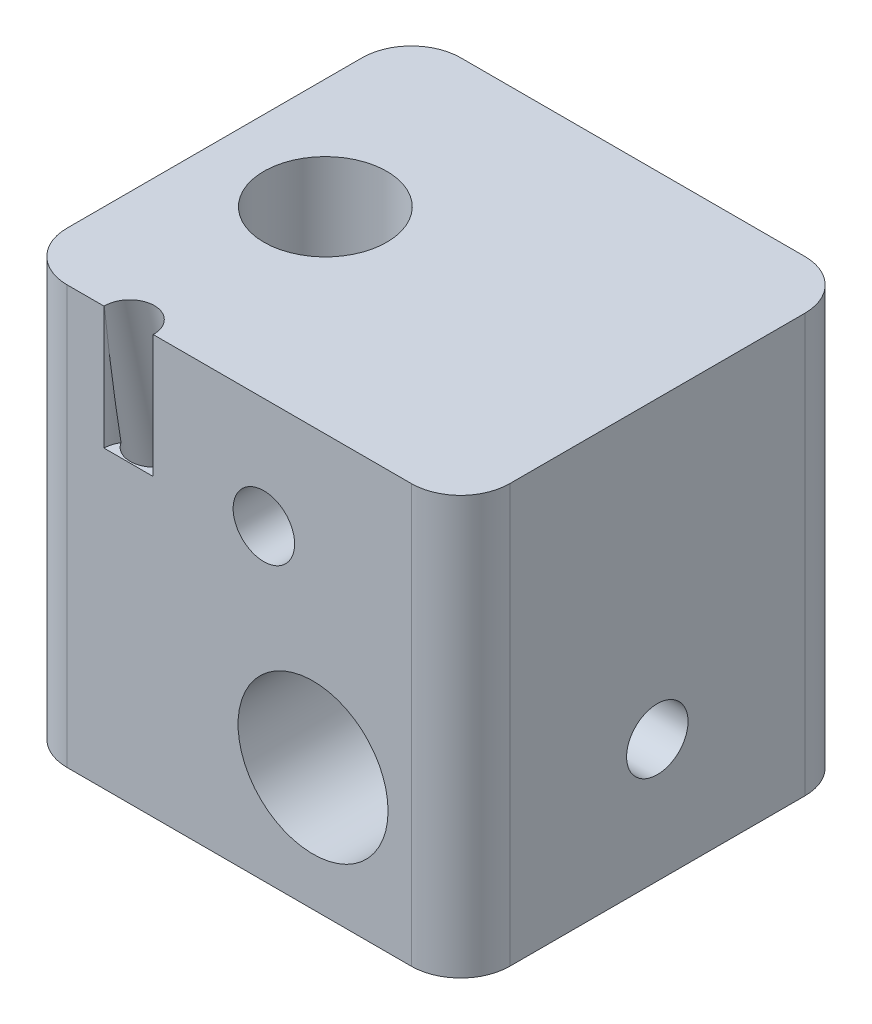
from build123d import *

# Parameters (mm, degrees)
BOSS_EXTRUDE1_DEPTH       = 17
SKETCH2_R                 = 3.05
CUT_EXTRUDE1_DEPTH        = 17
M3X0_5_TAPPED_HOLE1_D     = 2.5
M6X1_0_TAPPED_HOLE1_D     = 5
SKETCH7_R                 = 1
CUT_EXTRUDE2_DEPTH        = 5
M3X0_5_TAPPED_HOLE2_D     = 2.5
M3X0_5_TAPPED_HOLE2_DEPTH = 6
M3X0_5_TAPPED_HOLE2_TIP   = 0.751075774


with BuildPart() as part:
    # Sketch1 → Boss-Extrude1 (new body)
    with BuildSketch(Plane(origin=(0, 0, 0), x_dir=(1, 0, 0), z_dir=(0, 1, 0))):
        with BuildLine():
            Line((-7, 8), (7, 8))
            ThreePointArc((7, 8), (8.414213562, 7.414213562), (9, 6))
            Line((9, 6), (9, -6))
            ThreePointArc((9, -6), (8.414213562, -7.414213562), (7, -8))
            Line((7, -8), (-7, -8))
            ThreePointArc((-7, -8), (-8.414213562, -7.414213562), (-9, -6))
            Line((-9, -6), (-9, 6))
            ThreePointArc((-9, 6), (-8.414213562, 7.414213562), (-7, 8))
        make_face()
    extrude(amount=BOSS_EXTRUDE1_DEPTH)

    # Sketch2 → Cut-Extrude1 (cut, through all)
    with BuildSketch(Plane.XY.offset(8)):
        with Locations((3, 5)):
            Circle(SKETCH2_R)
    extrude(amount=-CUT_EXTRUDE1_DEPTH, mode=Mode.SUBTRACT)

    # M3x0.5 Tapped Hole1 (through all)
    with Locations(Plane.XY.offset(8)):
        with Locations((1, 12.5)):
            Hole(M3X0_5_TAPPED_HOLE1_D / 2)

    # M6x1.0 Tapped Hole1 (through all)
    with Locations(Plane(origin=(0, 17, 0), x_dir=(-1, 0, 0), z_dir=(0, 1, 0))):
        with Locations((4.5, 0)):
            Hole(M6X1_0_TAPPED_HOLE1_D / 2)

    # Sketch7 → Cut-Extrude2 (cut)
    with BuildSketch(Plane(origin=(0, 17, 0), x_dir=(1, 0, 0), z_dir=(0, 1, 0))):
        with Locations((-4.5, -8)):
            Circle(SKETCH7_R)
    extrude(amount=-CUT_EXTRUDE2_DEPTH, mode=Mode.SUBTRACT)

    # Sketch8 → Cut-Revolve1 (revolve, cut)
    with BuildSketch(Plane.ZY.offset(4.5), mode=Mode.PRIVATE) as cut_revolve1_sk:
        Polygon((4.796926452, 2.030181318), (5.9, 2.41), (9.273428811, 18.280734757), (8.29528121, 18.488646447), align=None)
    revolve(cut_revolve1_sk.sketch.rotate(Axis((-4.5, 1.132659385, 4.606152276), (0, 0.978147601, 0.207911691)), 180), axis=Axis((-4.5, 1.132659385, 4.606152276), (0, 0.978147601, 0.207911691)), mode=Mode.SUBTRACT)  # turned: the seam where the file's is

    # M3x0.5 Tapped Hole2
    with Locations(Plane(origin=(9, 0, 0), x_dir=(0, 0, -1), z_dir=(1, 0, 0))):
        with Locations((0, 5)):
            Hole(M3X0_5_TAPPED_HOLE2_D / 2, depth=M3X0_5_TAPPED_HOLE2_DEPTH)
            with Locations((0, 0, -(M3X0_5_TAPPED_HOLE2_DEPTH + M3X0_5_TAPPED_HOLE2_TIP / 2))):  # 118° drill point
                Cone(0, M3X0_5_TAPPED_HOLE2_D / 2, M3X0_5_TAPPED_HOLE2_TIP, mode=Mode.SUBTRACT)


solid = part.part
